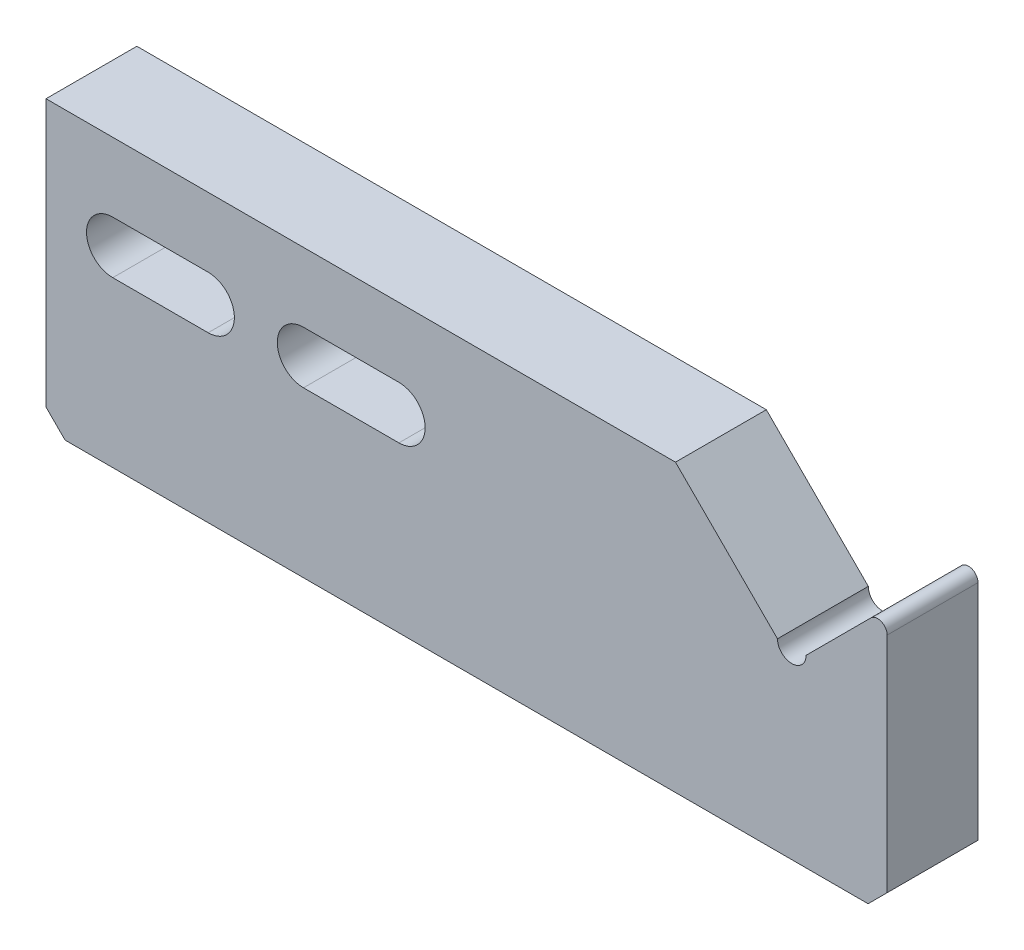
from build123d import *

# Parameters (mm, degrees)
BOSS_EXTRUDE1_DEPTH      = 6
BOSS_EXTRUDE1_DEPTH_BACK = 3.525
FILLET1_R                = 1
CHAMFER1_SIZE            = 2
CHAMFER2_SIZE            = 0.5


with BuildPart() as part:
    # Sketch1 → Boss-Extrude1 (new body, two sides)
    with BuildSketch(Plane.XY) as boss_extrude1_sk:
        with BuildLine():
            Line((-10, 267.218866814), (-18.5, 258.718866814))
            ThreePointArc((-18.5, 258.718866814), (-20, 257.218866814), (-21.5, 258.718866814))
            Line((-21.5, 258.718866814), (-32.192388155, 269.41125497))
            Line((-32.192388155, 269.41125497), (-98.192388155, 269.41125497))
            Line((-98.192388155, 269.41125497), (-98.192388155, 239.41125497))
            Line((-98.192388155, 239.41125497), (-10, 239.41125497))
            Line((-10, 239.41125497), (-10, 267.218866814))
        make_face()
        with BuildLine():
            Line((-81.192388155, 262.16125497), (-91.192388155, 262.16125497))
            ThreePointArc((-91.192388155, 262.16125497), (-93.942388155, 259.41125497), (-91.192388155, 256.66125497))
            Line((-91.192388155, 256.66125497), (-81.192388155, 256.66125497))
            ThreePointArc((-81.192388155, 256.66125497), (-78.442388155, 259.41125497), (-81.192388155, 262.16125497))
        make_face(mode=Mode.SUBTRACT)
        with BuildLine():
            Line((-61.192388155, 262.16125497), (-71.192388155, 262.16125497))
            ThreePointArc((-71.192388155, 262.16125497), (-73.942388155, 259.41125497), (-71.192388155, 256.66125497))
            Line((-71.192388155, 256.66125497), (-61.192388155, 256.66125497))
            ThreePointArc((-61.192388155, 256.66125497), (-58.442388155, 259.41125497), (-61.192388155, 262.16125497))
        make_face(mode=Mode.SUBTRACT)
    extrude(amount=BOSS_EXTRUDE1_DEPTH)
    extrude(boss_extrude1_sk.sketch, amount=-BOSS_EXTRUDE1_DEPTH_BACK)

    # Fillet1
    fillet1_edges = [part.edges().sort_by_distance(p)[0] for p in [
        (-10, 267.218866814, 1.2375),
    ]]
    fillet(fillet1_edges, radius=FILLET1_R)

    # Chamfer1
    chamfer1_edges = [part.edges().sort_by_distance(p)[0] for p in [
        (-10, 239.41125497, 1.2375),
        (-98.192388155, 239.41125497, 1.2375),
    ]]
    chamfer(chamfer1_edges, length=CHAMFER1_SIZE)

    # Sketch3 → Cut-Revolve1 (revolve, cut)
    with BuildSketch(Plane(origin=(0, 0, 1.2375), x_dir=(-1, 0, 0), z_dir=(0, 0, -1))):
        Polygon((98.192388155, 250.91125497), (78.192388155, 250.91125497), (77.326362752, 249.41125497), (98.192388155, 249.41125497), align=None)
    revolve(axis=Axis((-98.192388155, 249.41125497, 1.2375), (-1, 0, 0)), mode=Mode.SUBTRACT)

    # Chamfer2
    chamfer2_edges = [part.edges().sort_by_distance(p)[0] for p in [
        (-98.192388155, 247.91125497, 1.2375),
    ]]
    chamfer(chamfer2_edges, length=CHAMFER2_SIZE)


solid = part.part
